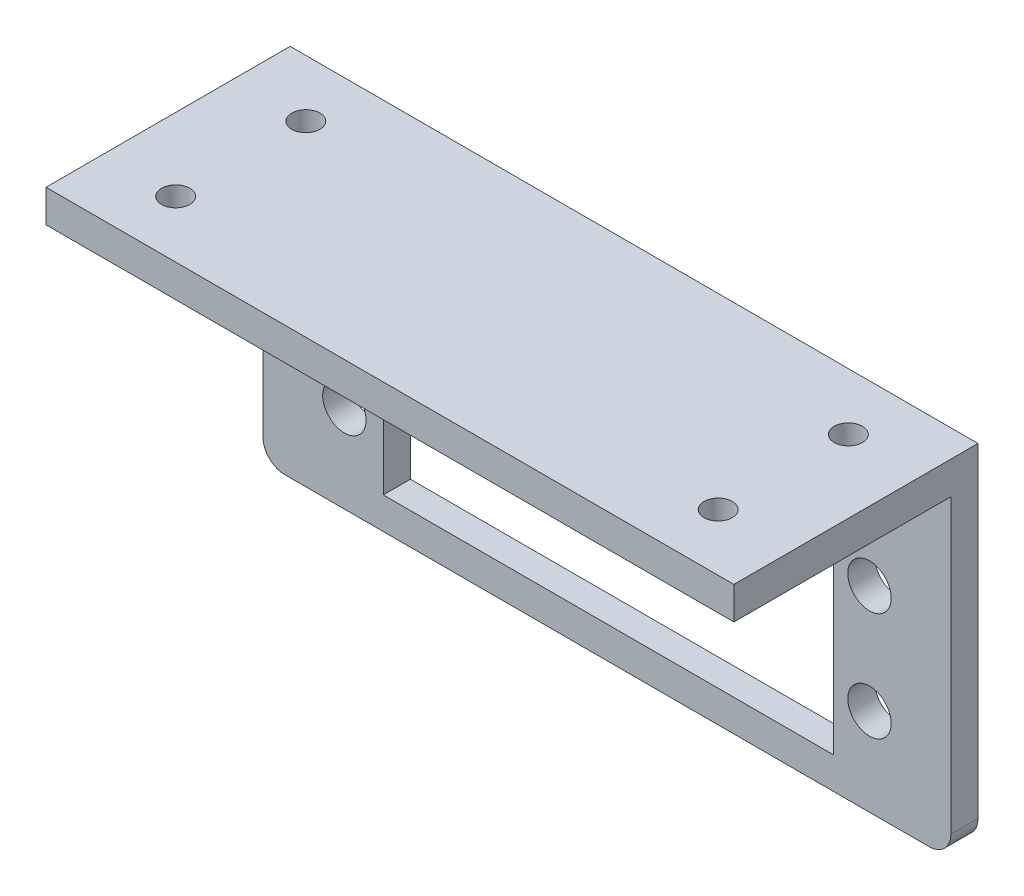
from build123d import *

# Parameters (mm, degrees)
SKETCH_1_R          = 2
SKETCH_1_R_2        = 2.000000001
SKETCH_1_W          = 41.5
SKETCH_1_H          = 20.5
EXTRUDE_1_DEPTH     = 2.5
SKETCH_2_W          = 63.400042917
SKETCH_2_H          = 3
EXTRUDE_2_DEPTH     = 20
SKETCH_3_R          = 1.3
CUT_EXTRUDE_1_DEPTH = 3


with BuildPart() as part:
    # 草图1 → 凸台-拉伸1 (new body)
    with BuildSketch(Plane.XY):
        with BuildLine():
            Line((9.102779232, -4.360253516), (68.502822149, -4.360253516))
            ThreePointArc((68.502822149, -4.360253516), (69.917035712, -3.774467079), (70.502822149, -2.360253516))
            Line((70.502822149, -2.360253516), (70.502822149, 27.577468612))
            Line((70.502822149, 27.577468612), (7.102779232, 27.577468612))
            Line((7.102779232, 27.577468612), (7.102779232, -2.360253516))
            ThreePointArc((7.102779232, -2.360253516), (7.688565669, -3.774467079), (9.102779232, -4.360253516))
        make_face()
        with Locations((14.602780347, 13.71523364)):
            Circle(SKETCH_1_R, mode=Mode.SUBTRACT)
        with Locations((14.602779232, 3.71523364)):
            Circle(SKETCH_1_R, mode=Mode.SUBTRACT)
        with Locations((63.002822149, 3.71523364)):
            Circle(SKETCH_1_R_2, mode=Mode.SUBTRACT)
        with Locations((63.002821034, 13.71523364)):
            Circle(SKETCH_1_R, mode=Mode.SUBTRACT)
        with Locations((38.938588543, 8.81523364)):
            Rectangle(SKETCH_1_W, SKETCH_1_H, mode=Mode.SUBTRACT)
    extrude(amount=EXTRUDE_1_DEPTH)

    # 草图2 → 凸台-拉伸2 (add)
    with BuildSketch(Plane.XY.offset(2.5)):
        with Locations((38.802800691, 26.077468612)):
            Rectangle(SKETCH_2_W, SKETCH_2_H)
    extrude(amount=EXTRUDE_2_DEPTH)

    # 草图3 → 切除-拉伸1 (cut)
    with BuildSketch(Plane(origin=(0, 27.577468612, 0), x_dir=(1, 0, 0), z_dir=(0, 1, 0))):
        with Locations((13.80280069, -5.25)):
            Circle(SKETCH_3_R)
        with Locations((63.80280069, -5.25)):
            Circle(SKETCH_3_R)
        with Locations((63.80280069, -17.25)):
            Circle(SKETCH_3_R)
        with Locations((13.80280069, -17.25)):
            Circle(SKETCH_3_R)
    extrude(amount=-CUT_EXTRUDE_1_DEPTH, mode=Mode.SUBTRACT)


solid = part.part
